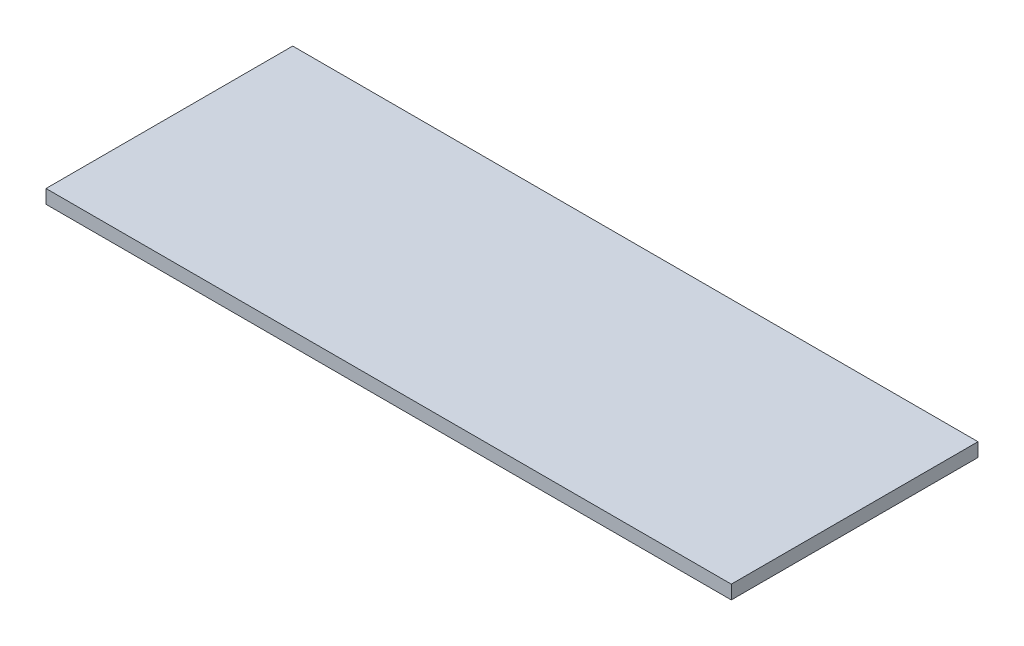
from build123d import *

# Parameters (mm, degrees)
SKETCH1_W           = 250
SKETCH1_H           = 90
BOSS_EXTRUDE1_DEPTH = 5


with BuildPart() as part:
    # Sketch1 → Boss-Extrude1 (new body)
    with BuildSketch(Plane(origin=(0, 0, 0), x_dir=(1, 0, 0), z_dir=(0, 1, 0))):
        Rectangle(SKETCH1_W, SKETCH1_H)
    extrude(amount=BOSS_EXTRUDE1_DEPTH)


solid = part.part
